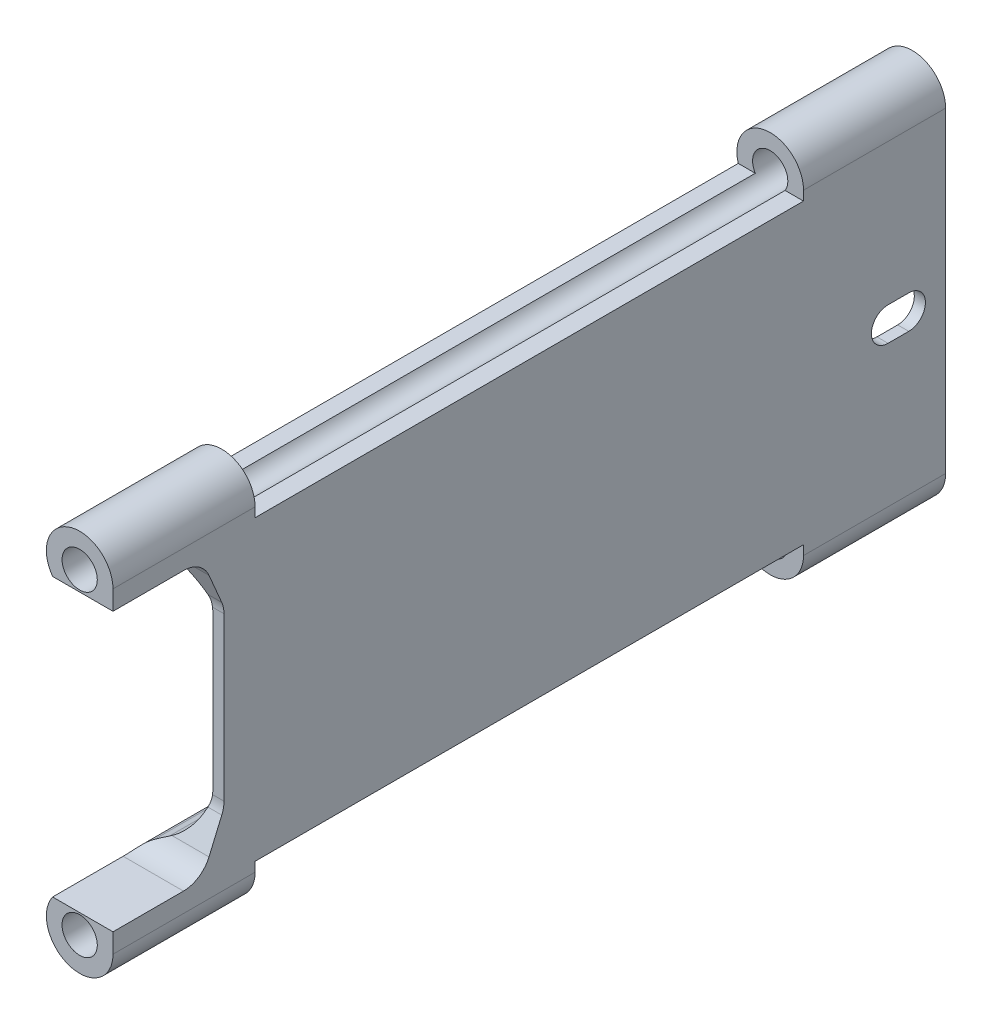
from build123d import *

# Parameters (mm, degrees)
CROQUIS1_R              = 3.175
SALIENTE_EXTRUIR1_DEPTH = 150
REDONDEO1_R             = 10
CORTAR_EXTRUIR1_DEPTH   = 13
REDONDEO2_R             = 5
CROQUIS3_W              = 98.791812306
CROQUIS3_H              = 18.145434914
CORTAR_EXTRUIR2_DEPTH   = 13.0000001
CORTAR_EXTRUIR3_DEPTH   = 3.0000001


with BuildPart() as part:
    # Croquis1 → Saliente-Extruir1 (new body)
    with BuildSketch(Plane.XY):
        with BuildLine():
            Line((-2, 19.285827964), (-8.98691391, 23.296314259))
            ThreePointArc((-8.98691391, 23.296314259), (-9.006535925, 33.69237342), (0, 28.5))
            Line((0, 28.5), (0, -28.5))
            ThreePointArc((0, -28.5), (-9.006535925, -33.69237342), (-8.98691391, -23.296314259))
            Line((-8.98691391, -23.296314259), (-2, -19.285827964))
            Line((-2, -19.285827964), (-2, 19.285827964))
        make_face()
        with Locations((-6, 28.5)):
            Circle(CROQUIS1_R, mode=Mode.SUBTRACT)
        with Locations((-6, -28.5)):
            Circle(CROQUIS1_R, mode=Mode.SUBTRACT)
    extrude(amount=-SALIENTE_EXTRUIR1_DEPTH)

    # Redondeo1
    redondeo1_edges = [part.edges().sort_by_distance(p)[0] for p in [
        (-2, -19.285827964, -75),
        (-2, 19.285827964, -75),
    ]]
    fillet(redondeo1_edges, radius=REDONDEO1_R)

    # Croquis2 → Cortar-Extruir1 (cut, through all)
    with BuildSketch(Plane(origin=(0, 0, 0), x_dir=(0, 0, -1), z_dir=(1, 0, 0))):
        Polygon((16, 25), (20, 15.646846929), (20, -15.646846929), (16, -25), (-29.873538988, -25), (-29.873538988, 25), align=None)
    extrude(amount=-CORTAR_EXTRUIR1_DEPTH, mode=Mode.SUBTRACT)

    # Redondeo2
    redondeo2_edges = [part.edges().sort_by_distance(p)[0] for p in [
        (-1.117074127, 15.646846929, -20),
        (-1.117074127, -15.646846929, -20),
        (-5.436698586, -25, -16),
        (-5.436698586, 25, -16),
    ]]
    fillet(redondeo2_edges, radius=REDONDEO2_R)

    # Croquis3 → Cortar-Extruir2 (cut, through all)
    with BuildSketch(Plane(origin=(0, 0, 0), x_dir=(0, 0, -1), z_dir=(1, 0, 0))):
        with Locations((75, 35.875128035)):
            Rectangle(CROQUIS3_W, CROQUIS3_H)
        with Locations((75, -35.875128035)):
            Rectangle(CROQUIS3_W, CROQUIS3_H)
    extrude(amount=-CORTAR_EXTRUIR2_DEPTH, mode=Mode.SUBTRACT)

    # Croquis4 → Cortar-Extruir3 (cut, through all)
    with BuildSketch(Plane.ZY.offset(2)):
        with BuildLine():
            Line((-143.359821197, 3), (-139.627206237, 3))
            ThreePointArc((-139.627206237, 3), (-136.627206237, 0), (-139.627206237, -3))
            Line((-139.627206237, -3), (-143.359821197, -3))
            ThreePointArc((-143.359821197, -3), (-146.359821197, 0), (-143.359821197, 3))
        make_face()
    extrude(amount=-CORTAR_EXTRUIR3_DEPTH, mode=Mode.SUBTRACT)


solid = part.part
